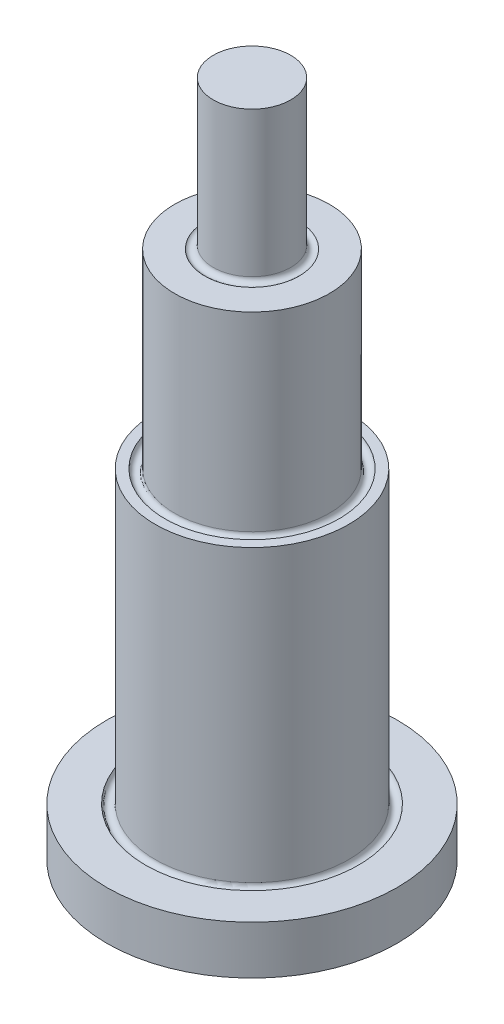
from build123d import *


with BuildPart() as part:
    # Sketch1 → Revolve1 (revolve)
    with BuildSketch(Plane.XY):
        with BuildLine():
            Line((-9, 0), (-10, 0))
            Line((-10, 0), (-10, -30))
            ThreePointArc((-10, -30), (-10.5, -30.5), (-11, -30))
            Line((-11, -30), (-15, -30))
            Line((-15, -30), (-15, -35))
            Line((-15, -35), (0, -35))
            Line((0, -35), (0, -30))
            Line((0, -30), (0, 0))
            Line((0, 0), (0, 20))
            Line((0, 20), (0, 35))
            Line((0, 35), (-4, 35))
            Line((-4, 35), (-4, 20))
            ThreePointArc((-4, 20), (-4.320844675, 19.53319879), (-4.871613477, 19.665480309))
            Line((-4.871613477, 19.665480309), (-8, 19.665480309))
            Line((-8, 19.665480309), (-8, 0))
            ThreePointArc((-8, 0), (-8.5, -0.5), (-9, 0))
        make_face()
    revolve(axis=Axis((0, 0, 0), (0, 1, 0)))


solid = part.part
